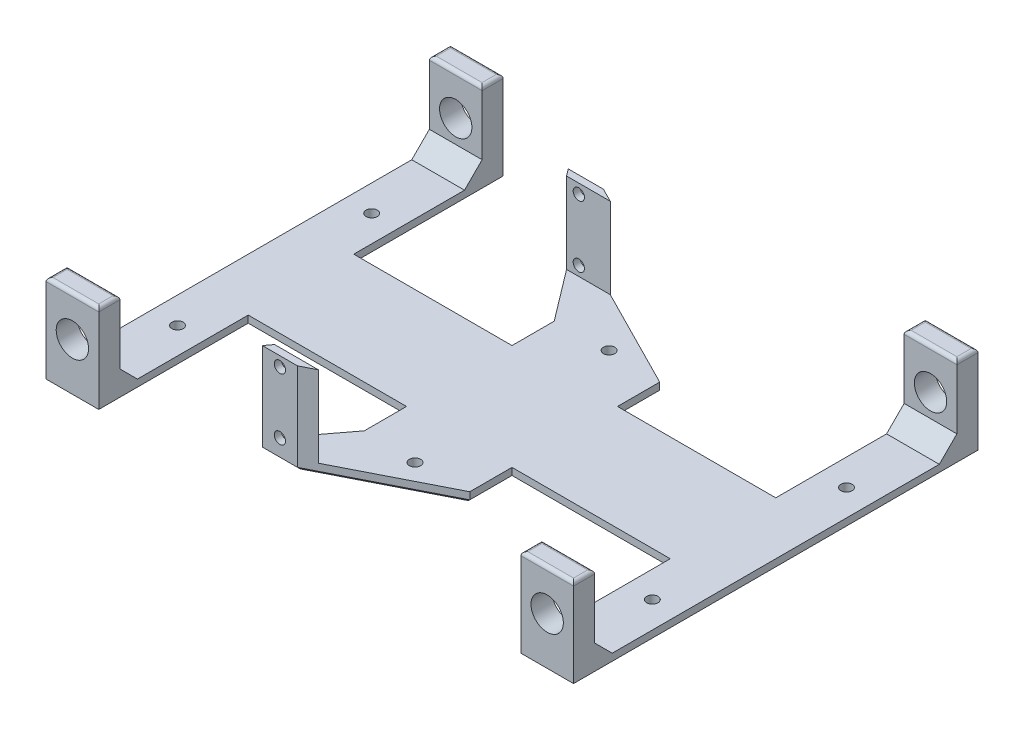
from build123d import *

# Parameters (mm, degrees)
SKETCH2_W           = 15
SKETCH2_H           = 30.5
SKETCH2_W_2         = 7.5
SKETCH2_H_2         = 30
SKETCH2_W_3         = 45
SKETCH2_W_4         = 30
SKETCH2_H_3         = 12
BOSS_EXTRUDE1_DEPTH = 3
SKETCH3_W           = 15
SKETCH3_H           = 6
BOSS_EXTRUDE2_DEPTH = 23
SKETCH4_R           = 1.6
CUT_EXTRUDE1_DEPTH  = 23
SKETCH5_R           = 4.6
CUT_EXTRUDE2_DEPTH  = 23
SKETCH6_R           = 1.6
CUT_EXTRUDE3_DEPTH  = 23
CHAMFER1_SIZE       = 1
FILLET1_R           = 1
CHAMFER2_SIZE       = 5


with BuildPart() as part:
    # Sketch2 → Boss-Extrude1 (new body)
    with BuildSketch(Plane(origin=(0, 0, 0), x_dir=(1, 0, 0), z_dir=(0, 1, 0))):
        with Locations((-67.5, -42.25)):
            Rectangle(SKETCH2_W, SKETCH2_H)
        Polygon((-60, 57.5), (-75, 57.5), (-75, -27), (-60, -27), (-60, -15), (-67.5, -15), (-67.5, 15), (-60, 15), (-60, 27), align=None)
        with Locations((-63.75, 0)):
            Rectangle(SKETCH2_W_2, SKETCH2_H_2)
        with Locations((-37.5, 0)):
            Rectangle(SKETCH2_W_3, SKETCH2_H_2)
        Rectangle(SKETCH2_W_4, SKETCH2_H_2)
        Polygon((-15, 27), (-15, 15), (15, 15), (15, 27), (-17.5, 43.5), (-27.5, 43.5), align=None)
        Polygon((-27.5, -43.5), (-15, -27), (15, -27), (-17.5, -43.5), align=None)
        with Locations((0, -21)):
            Rectangle(SKETCH2_W_4, SKETCH2_H_3)
        with Locations((37.5, 0)):
            Rectangle(SKETCH2_W_3, SKETCH2_H_2)
        with Locations((63.75, 0)):
            Rectangle(SKETCH2_W_2, SKETCH2_H_2)
        Polygon((60, 27), (60, 15), (67.5, 15), (67.5, -15), (60, -15), (60, -27), (75, -27), (75, 57.5), (60, 57.5), align=None)
        with Locations((67.5, -42.25)):
            Rectangle(SKETCH2_W, SKETCH2_H)
    extrude(amount=BOSS_EXTRUDE1_DEPTH)

    # Sketch3 → Boss-Extrude2 (add)
    with BuildSketch(Plane(origin=(0, 3, 0), x_dir=(1, 0, 0), z_dir=(0, 1, 0))):
        with Locations((-67.5, 54.5)):
            Rectangle(SKETCH3_W, SKETCH3_H)
        Polygon((-17.5, 43.5), (-27.5, 43.5), (-25.984848485, 41.5), (-13.560606061, 41.5), align=None)
        with Locations((67.5, 54.5)):
            Rectangle(SKETCH3_W, SKETCH3_H)
    extrude(amount=BOSS_EXTRUDE2_DEPTH)

    # Sketch4 → Cut-Extrude1 (cut)
    with BuildSketch(Plane(origin=(0, 0, -43.5), x_dir=(-1, 0, 0), z_dir=(0, 0, -1))):
        with Locations((22.5, 23.25)):
            Circle(SKETCH4_R)
        with Locations((22.5, 5.75)):
            Circle(SKETCH4_R)
    extrude(amount=-CUT_EXTRUDE1_DEPTH, mode=Mode.SUBTRACT)

    # Sketch5 → Cut-Extrude2 (cut)
    with BuildSketch(Plane(origin=(0, 0, -57.5), x_dir=(-1, 0, 0), z_dir=(0, 0, -1))):
        with Locations((67.5, 14.5)):
            Circle(SKETCH5_R)
    cut_extrude2 = extrude(amount=-CUT_EXTRUDE2_DEPTH, mode=Mode.SUBTRACT)

    # Mirror3: Cut-Extrude2 across plane
    add(cut_extrude2.mirror(Plane(origin=(0, 0, 0), x_dir=(0, 0, 1), z_dir=(1, 0, 0))), mode=Mode.SUBTRACT)

    # Mirror4: part across plane


with BuildPart() as part_1:
    add(part.part)
    add(part.part.mirror(Plane.XY))

    # Sketch6 → Cut-Extrude3 (cut)
    with BuildSketch(Plane(origin=(0, 3, 0), x_dir=(1, 0, 0), z_dir=(0, 1, 0))):
        with Locations((-67.5, 27.6)):
            Circle(SKETCH6_R)
        with Locations((0, 27.6)):
            Circle(SKETCH6_R)
        with Locations((67.5, 27.6)):
            Circle(SKETCH6_R)
        with Locations((67.5, -27.6)):
            Circle(SKETCH6_R)
        with Locations((0, -27.6)):
            Circle(SKETCH6_R)
        with Locations((-67.5, -27.6)):
            Circle(SKETCH6_R)
    extrude(amount=-CUT_EXTRUDE3_DEPTH, mode=Mode.SUBTRACT)

    # Chamfer1
    chamfer1_edges = [part_1.edges().sort_by_distance(p)[0] for p in [
        (-67.5, 0, 57.5),
        (-75, 0, 0),
        (-67.5, 0, -57.5),
        (-60, 0, -36.25),
        (-37.5, 0, -15),
        (-15, 0, -21),
        (-21.25, 0, -35.25),
        (-22.5, 0, -43.5),
        (-1.25, 0, -35.25),
        (15, 0, -21),
        (37.5, 0, -15),
        (60, 0, -36.25),
        (67.5, 0, -57.5),
        (75, 0, 0),
        (67.5, 0, 57.5),
        (60, 0, 36.25),
        (37.5, 0, 15),
        (15, 0, 21),
        (-1.25, 0, 35.25),
        (-22.5, 0, 43.5),
        (-21.25, 0, 35.25),
        (-15, 0, 21),
        (-37.5, 0, 15),
        (-60, 0, 36.25),
    ]]
    chamfer(chamfer1_edges, length=CHAMFER1_SIZE)

    # Fillet1
    fillet1_edges = [part_1.edges().sort_by_distance(p)[0] for p in [
        (60, 26, 54.5),
        (75, 26, 54.5),
        (67.5, 26, 51.5),
        (67.5, 26, 57.5),
        (75, 26, -54.5),
        (60, 26, -54.5),
        (67.5, 26, -51.5),
        (67.5, 26, -57.5),
        (-67.5, 26, -57.5),
        (-60, 26, -54.5),
        (-67.5, 26, -51.5),
        (-75, 26, -54.5),
        (-75, 26, 54.5),
        (-60, 26, 54.5),
        (-67.5, 26, 51.5),
        (-67.5, 26, 57.5),
    ]]
    fillet(fillet1_edges, radius=FILLET1_R)

    # Chamfer2
    chamfer2_edges = [part_1.edges().sort_by_distance(p)[0] for p in [
        (-67.5, 3, 51.5),
        (67.5, 3, 51.5),
        (67.5, 3, -51.5),
        (-67.5, 3, -51.5),
    ]]
    chamfer(chamfer2_edges, length=CHAMFER2_SIZE)


solid = part_1.part
